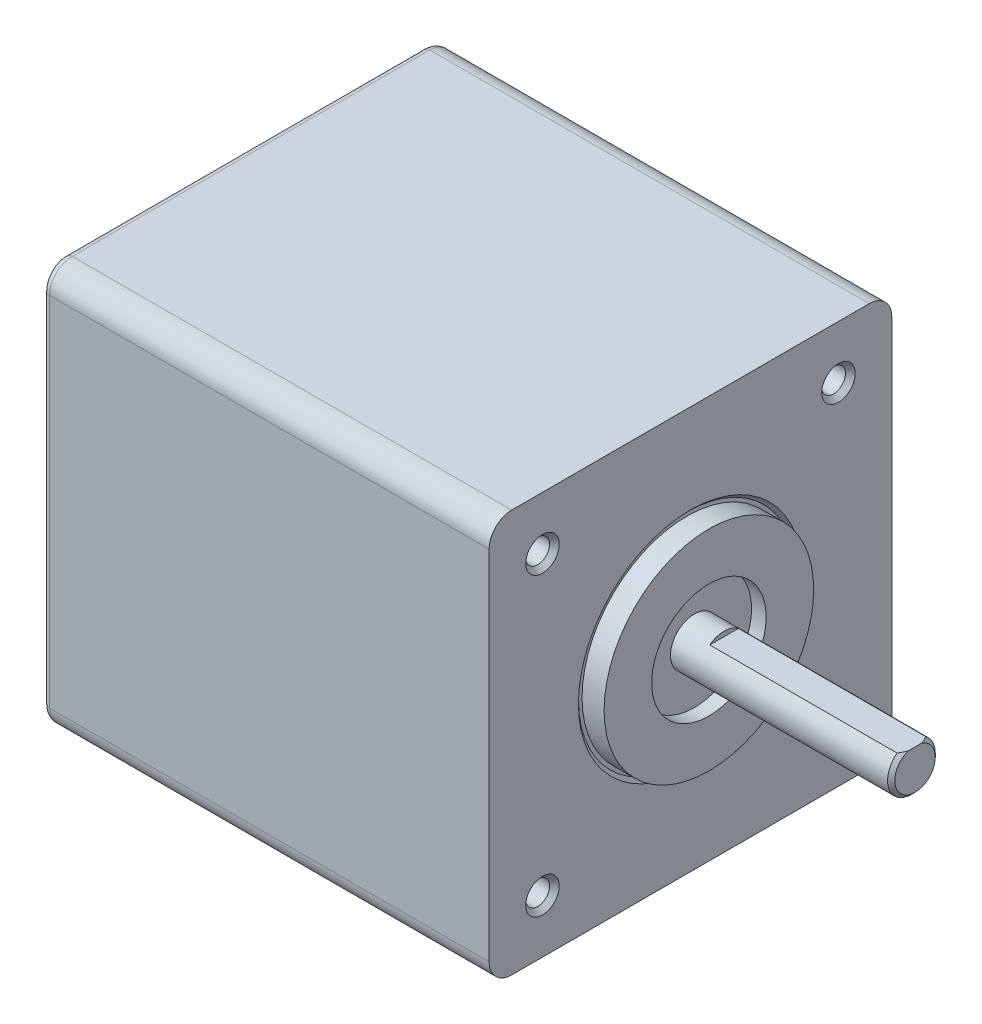
from build123d import *

# Parameters (mm, degrees)
SKETCH1_W               = 42.164
SKETCH1_H               = 42.164
BOSS_EXTRUDE1_DEPTH     = 46.7868
FILLET1_R               = 2.3622
SKETCH2_R               = 10.975
BOSS_EXTRUDE2_DEPTH     = 1.9304
SKETCH3_R               = 2.5
BOSS_EXTRUDE3_DEPTH     = 21.59
CHAMFER1_SIZE           = 0.381
SKETCH18_R              = 5.9944
SKETCH18_R_2            = 2.5
CUT_EXTRUDE8_DEPTH      = 1.524
SKETCH5_R               = 1.2446
CUT_EXTRUDE1_DEPTH      = 29.6004
CUT_EXTRUDE1_DEPTH_BACK = 42.7068
FILLET4_R               = 0.762
CHAMFER3_SIZE           = 0.508
SKETCH19_W              = 40
SKETCH19_H              = 27.280293062
CUT_EXTRUDE9_DEPTH      = 20.082


with BuildPart() as part:
    # Sketch1 → Boss-Extrude1 (new body)
    with BuildSketch(Plane(origin=(0, 0, 0), x_dir=(0, 0, -1), z_dir=(1, 0, 0))):
        Rectangle(SKETCH1_W, SKETCH1_H)
    extrude(amount=-BOSS_EXTRUDE1_DEPTH)

    # Fillet1
    fillet1_edges = [part.edges().sort_by_distance(p)[0] for p in [
        (-23.3934, 21.082, 21.082),
        (-23.3934, 21.082, -21.082),
        (-23.3934, -21.082, -21.082),
        (-23.3934, -21.082, 21.082),
    ]]
    fillet(fillet1_edges, radius=FILLET1_R)

    # Sketch2 → Boss-Extrude2 (add)
    with BuildSketch(Plane(origin=(0, 0, 0), x_dir=(0, 0, -1), z_dir=(1, 0, 0))):
        Circle(SKETCH2_R)
    extrude(amount=BOSS_EXTRUDE2_DEPTH)

    # Sketch10 → Cut-Revolve1 (revolve, cut)
    with BuildSketch(Plane.XY):
        Polygon((0, 10.975), (-0.381, 10.975), (-0.381, 11.356), (0, 11.737), align=None)
    revolve(axis=Axis((0, 0, 0), (1, 0, 0)), mode=Mode.SUBTRACT)

    # Sketch3 → Boss-Extrude3 (add)
    with BuildSketch(Plane(origin=(1.9304, 0, 0), x_dir=(0, 0, -1), z_dir=(1, 0, 0))):
        Circle(SKETCH3_R)
    extrude(amount=BOSS_EXTRUDE3_DEPTH)

    # Chamfer1
    chamfer1_edges = [part.edges().sort_by_distance(p)[0] for p in [
        (23.5204, 0, 2.5),
    ]]
    chamfer(chamfer1_edges, length=CHAMFER1_SIZE)

    # Sketch18 → Cut-Extrude8 (cut)
    with BuildSketch(Plane(origin=(1.9304, 0, 0), x_dir=(0, 0, -1), z_dir=(1, 0, 0))):
        Circle(SKETCH18_R)
        Circle(SKETCH18_R_2, mode=Mode.SUBTRACT)
    extrude(amount=-CUT_EXTRUDE8_DEPTH, mode=Mode.SUBTRACT)

    # Sketch5 → Cut-Extrude1 (cut, two sides)
    with BuildSketch(Plane(origin=(-5.08, 0, 0), x_dir=(0, 0, -1), z_dir=(1, 0, 0))) as cut_extrude1_sk:
        with Locations((-15.5, 15.5)):
            Circle(SKETCH5_R)
        with Locations((-15.5, -15.5)):
            Circle(SKETCH5_R)
        with Locations((15.5, -15.5)):
            Circle(SKETCH5_R)
        with Locations((15.5, 15.5)):
            Circle(SKETCH5_R)
    extrude(amount=CUT_EXTRUDE1_DEPTH, mode=Mode.SUBTRACT)
    extrude(cut_extrude1_sk.sketch, amount=-CUT_EXTRUDE1_DEPTH_BACK, mode=Mode.SUBTRACT)

    # Fillet4
    fillet4_edges = [part.edges().sort_by_distance(p)[0] for p in [
        (-46.7868, -21.082, 0),
        (-46.7868, 0, -21.082),
        (-46.7868, 0, 21.082),
        (-46.7868, 21.082, 0),
        (-46.7868, 20.390127639, 20.390127639),
        (-46.7868, -20.390127639, 20.390127639),
        (-46.7868, 20.390127639, -20.390127639),
        (-46.7868, -20.390127639, -20.390127639),
    ]]
    fillet(fillet4_edges, radius=FILLET4_R)

    # Chamfer3
    chamfer3_edges = [part.edges().sort_by_distance(p)[0] for p in [
        (-46.7868, 15.5, 16.7446),
        (0, 15.5, 16.7446),
        (-46.7868, -15.5, 16.7446),
        (0, -15.5, 16.7446),
        (-46.7868, -15.5, -14.2554),
        (0, -15.5, -14.2554),
        (-46.7868, 15.5, -14.2554),
        (0, 15.5, -14.2554),
    ]]
    chamfer(chamfer3_edges, length=CHAMFER3_SIZE)

    # Sketch19 → Cut-Extrude9 (cut, through all)
    with BuildSketch(Plane(origin=(0, 2, 0), x_dir=(1, 0, 0), z_dir=(0, 1, 0))):
        with Locations((23.5204, 0)):
            Rectangle(SKETCH19_W, SKETCH19_H)
    extrude(amount=CUT_EXTRUDE9_DEPTH, mode=Mode.SUBTRACT)


solid = part.part
